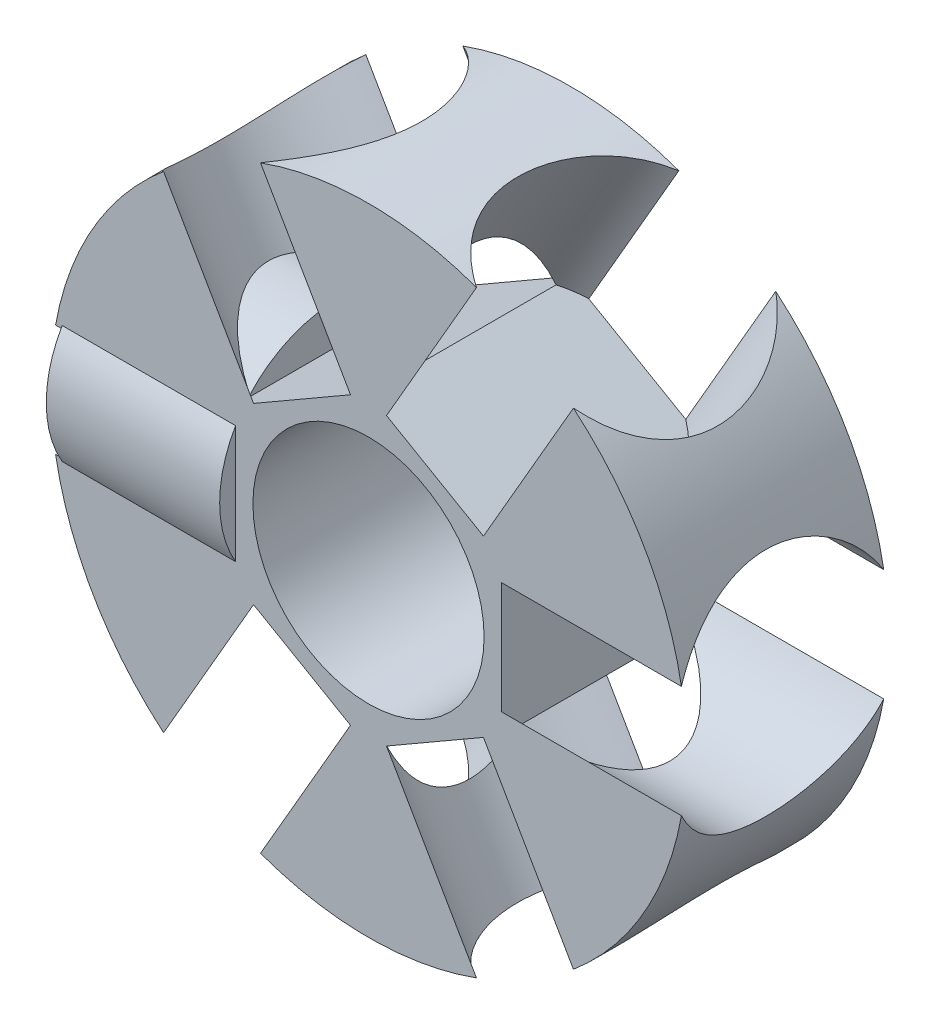
from build123d import *

# Parameters (mm, degrees)
SKETCH1_R           = 11
SKETCH1_R_2         = 4
BOSS_EXTRUDE1_DEPTH = 3.5
SKETCH2_R           = 4
CUT_EXTRUDE3_DEPTH  = 6.4
CIRPATTERN1_COUNT   = 6
SKETCH3_R           = 4.05
BOSS_EXTRUDE2_DEPTH = 6


with BuildPart() as part:
    # Sketch1 → Boss-Extrude1 (new, symmetric)
    with BuildSketch(Plane.XY):
        Circle(SKETCH1_R)
        Circle(SKETCH1_R_2, mode=Mode.SUBTRACT)
    extrude(amount=BOSS_EXTRUDE1_DEPTH, both=True)

    # Sketch2 → Cut-Extrude3 (cut)
    with BuildSketch(Plane(origin=(-11, -17.193061184, 0), x_dir=(0, -1, 0), z_dir=(1, 0, 0))):
        with Locations((-17.193061184, 0)):
            Circle(SKETCH2_R)
    cut_extrude3 = extrude(amount=CUT_EXTRUDE3_DEPTH, mode=Mode.SUBTRACT)

    # CirPattern1: Cut-Extrude3 ×6 about axis
    cirpattern1_axis = Axis((0, 0, 3.5), (0, 0, 1))
    for i in range(1, CIRPATTERN1_COUNT):
        add(cut_extrude3.rotate(cirpattern1_axis, i * 360 / CIRPATTERN1_COUNT), mode=Mode.SUBTRACT)

    # Sketch3 → Boss-Extrude2 (add)
    with BuildSketch(Plane(origin=(-4.6, 0, 0), x_dir=(0, -1, 0), z_dir=(-1, 0, 0))):
        Circle(SKETCH3_R)
    extrude(amount=BOSS_EXTRUDE2_DEPTH)


solid = part.part
